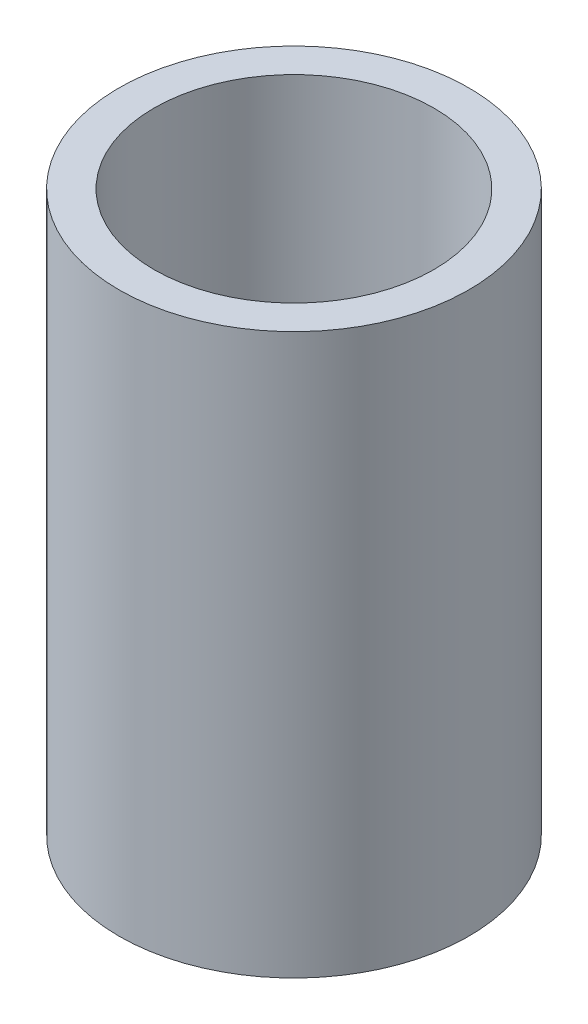
from build123d import *

# Parameters (mm, degrees)
SKETCH1_R           = 7.5
SKETCH1_R_2         = 6
BOSS_EXTRUDE1_DEPTH = 24


with BuildPart() as part:
    # Sketch1 → Boss-Extrude1 (new body)
    with BuildSketch(Plane(origin=(0, 0, 0), x_dir=(1, 0, 0), z_dir=(0, 1, 0))):
        Circle(SKETCH1_R)
        Circle(SKETCH1_R_2, mode=Mode.SUBTRACT)
    extrude(amount=BOSS_EXTRUDE1_DEPTH)


solid = part.part
